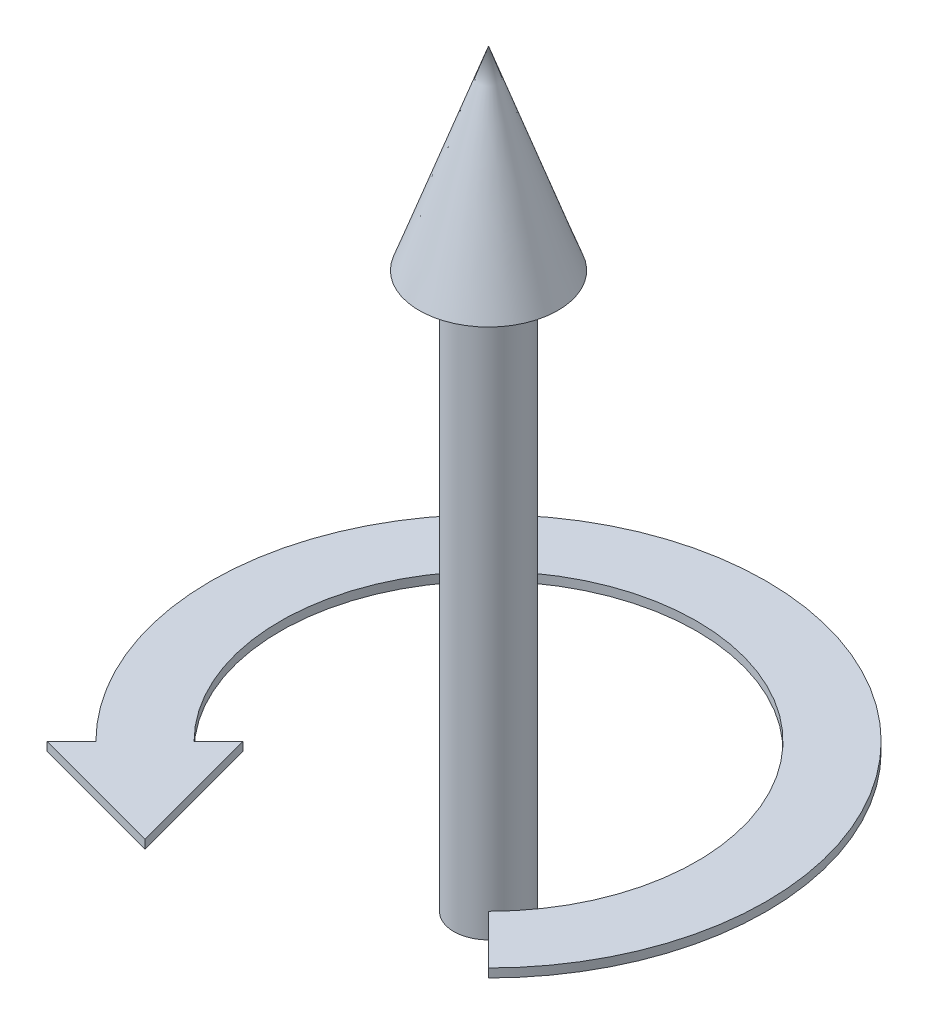
from build123d import *

# Parameters (mm, degrees)
SKETCH1_R           = 1.5875
BOSS_EXTRUDE1_DEPTH = 25.4
BOSS_EXTRUDE2_START = -6.35
BOSS_EXTRUDE2_DEPTH = 0.396875


with BuildPart() as part:
    # Sketch1 → Boss-Extrude1 (new body)
    with BuildSketch(Plane(origin=(0, 0, 0), x_dir=(1, 0, 0), z_dir=(0, 1, 0))):
        Circle(SKETCH1_R)
    extrude(amount=BOSS_EXTRUDE1_DEPTH)

    # Sketch3 → Revolve1 (revolve)
    with BuildSketch(Plane.XY):
        Polygon((0, 25.4), (0, 34.29), (3.175, 25.4), (1.5875, 25.4), align=None)
    revolve(axis=Axis((0, 25.4, 0), (0, 1, 0)))


with BuildPart() as body_2:
    # Sketch4 → Boss-Extrude2 (new body)
    with BuildSketch(Plane.XZ.offset(BOSS_EXTRUDE2_START)):
        with BuildLine():
            Line((-6.735192091, 6.735192091), (-5.612660076, 5.612660076))
            Line((-5.612660076, 5.612660076), (-3.969159139, 11.746289073))
            Line((-3.969159139, 11.746289073), (-10.102788136, 10.102788136))
            Line((-10.102788136, 10.102788136), (-8.980256121, 8.980256121))
            ThreePointArc((-8.980256121, 8.980256121), (0, -12.7), (8.980256121, 8.980256121))
            Line((8.980256121, 8.980256121), (6.735192091, 6.735192091))
            ThreePointArc((6.735192091, 6.735192091), (0, -9.525), (-6.735192091, 6.735192091))
        make_face()
    extrude(amount=-BOSS_EXTRUDE2_DEPTH)


solid = Compound([part.part, body_2.part])
